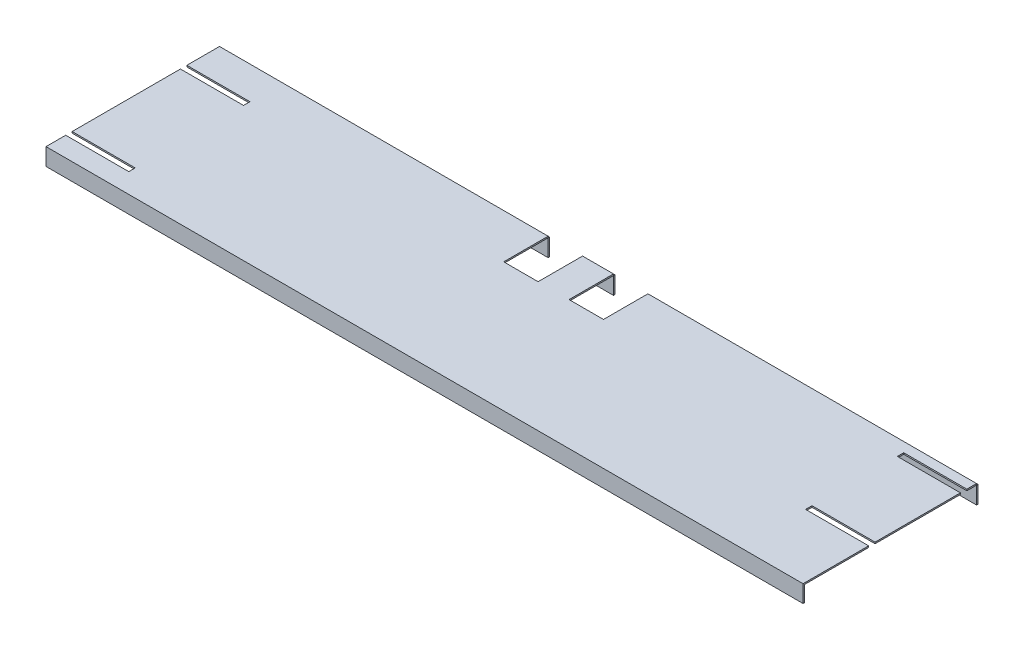
from build123d import *

# Parameters (mm, degrees)
SKETCH1_W           = 838.2
SKETCH1_H           = 190.5
BOSS_EXTRUDE1_DEPTH = 1.6002
SKETCH3_W           = 838.2
SKETCH3_H           = 19.05
BOSS_EXTRUDE2_DEPTH = 1.6002
SKETCH4_W           = 838.2
SKETCH4_H           = 19.05
BOSS_EXTRUDE3_DEPTH = 1.6002
SKETCH2_W           = 38.1
SKETCH2_H           = 50.8
CUT_EXTRUDE1_DEPTH  = 21.6502
SKETCH6_W           = 69.85
SKETCH6_H           = 7.112
CUT_EXTRUDE2_DEPTH  = 21.6502


with BuildPart() as part:
    # Sketch1 → Boss-Extrude1 (new body)
    with BuildSketch(Plane(origin=(0, 0, 0), x_dir=(1, 0, 0), z_dir=(0, 1, 0))):
        with Locations((419.1, -95.25)):
            Rectangle(SKETCH1_W, SKETCH1_H)
    extrude(amount=BOSS_EXTRUDE1_DEPTH)

    # Sketch3 → Boss-Extrude2 (add)
    with BuildSketch(Plane.XY.offset(190.5)):
        with Locations((419.1, -7.9248)):
            Rectangle(SKETCH3_W, SKETCH3_H)
    extrude(amount=BOSS_EXTRUDE2_DEPTH)


with BuildPart() as body_2:
    # Sketch4 → Boss-Extrude3 (new body)
    with BuildSketch(Plane(origin=(0, 0, 0), x_dir=(-1, 0, 0), z_dir=(0, 0, -1))):
        with Locations((-419.1, -9.525)):
            Rectangle(SKETCH4_W, SKETCH4_H)
    extrude(amount=BOSS_EXTRUDE3_DEPTH)


with BuildPart() as cut_extrude1_tool:
    # Sketch2 → Cut-Extrude1 (new body, through all)
    with BuildSketch(Plane(origin=(0, 1.6002, 0), x_dir=(1, 0, 0), z_dir=(0, 1, 0))):
        with Locations((382.905, -23.7998)):
            Rectangle(SKETCH2_W, SKETCH2_H)
        with Locations((455.295, -23.7998)):
            Rectangle(SKETCH2_W, SKETCH2_H)
    extrude(amount=-CUT_EXTRUDE1_DEPTH)


with BuildPart() as part_1:
    add(part.part)

    # Cut-Extrude1: cut by cut_extrude1_tool
    add(cut_extrude1_tool.part, mode=Mode.SUBTRACT)

    # Sketch6 → Cut-Extrude2 (cut, through all)
    with BuildSketch(Plane(origin=(0, 1.6002, 0), x_dir=(1, 0, 0), z_dir=(0, 1, 0))):
        with Locations((34.925, -39.7002)):
            Rectangle(SKETCH6_W, SKETCH6_H)
        with Locations((34.925, -166.7002)):
            Rectangle(SKETCH6_W, SKETCH6_H)
        with Locations((803.275, -14.3002)):
            Rectangle(SKETCH6_W, SKETCH6_H)
        with Locations((803.275, -115.9002)):
            Rectangle(SKETCH6_W, SKETCH6_H)
    extrude(amount=-CUT_EXTRUDE2_DEPTH, mode=Mode.SUBTRACT)


with BuildPart() as body_2_1:
    add(body_2.part)

    # Cut-Extrude1: cut by cut_extrude1_tool
    add(cut_extrude1_tool.part, mode=Mode.SUBTRACT)


solid = Compound([part_1.part, body_2_1.part])
